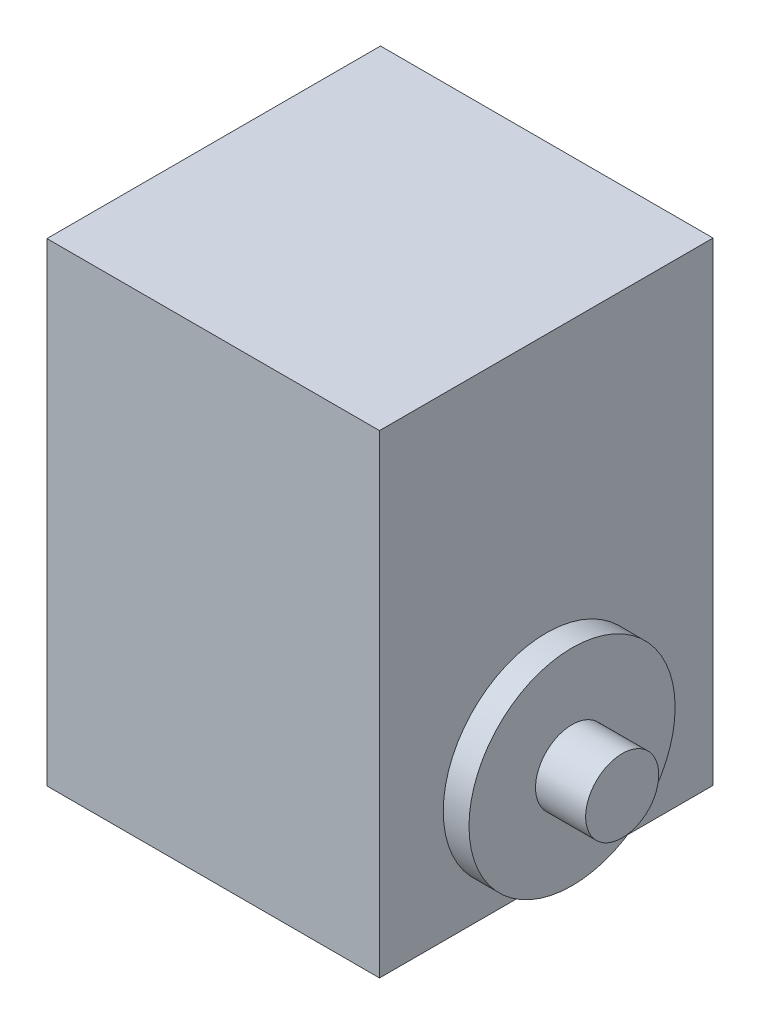
from build123d import *

# Parameters (mm, degrees)
SKETCH2_W           = 35.5
SKETCH2_H           = 35.6
BOSS_EXTRUDE1_DEPTH = 50.6
SKETCH3_R           = 11
BOSS_EXTRUDE2_DEPTH = 2.75
SKETCH4_R           = 3.9
BOSS_EXTRUDE3_DEPTH = 5.35


with BuildPart() as part:
    # Sketch2 → Boss-Extrude1 (new body)
    with BuildSketch(Plane(origin=(0, -12, 0), x_dir=(-1, 0, 0), z_dir=(0, 1, 0))):
        Rectangle(SKETCH2_W, SKETCH2_H)
    extrude(amount=BOSS_EXTRUDE1_DEPTH)

    # Sketch3 → Boss-Extrude2 (add)
    with BuildSketch(Plane(origin=(17.75, 0, 0), x_dir=(0, 0, -1), z_dir=(1, 0, 0))):
        Circle(SKETCH3_R)
    boss_extrude2 = extrude(amount=BOSS_EXTRUDE2_DEPTH)

    # Sketch4 → Boss-Extrude3 (add)
    with BuildSketch(Plane(origin=(20.5, 0, 0), x_dir=(0, 0, -1), z_dir=(1, 0, 0))):
        Circle(SKETCH4_R)
    boss_extrude3 = extrude(amount=BOSS_EXTRUDE3_DEPTH)

    # Mirror1: Boss-Extrude2, Boss-Extrude3 across plane
    add(boss_extrude2.mirror(Plane(origin=(0, 0, 0), x_dir=(0, 0, 1), z_dir=(1, 0, 0))))
    add(boss_extrude3.mirror(Plane(origin=(0, 0, 0), x_dir=(0, 0, 1), z_dir=(1, 0, 0))))


solid = part.part
